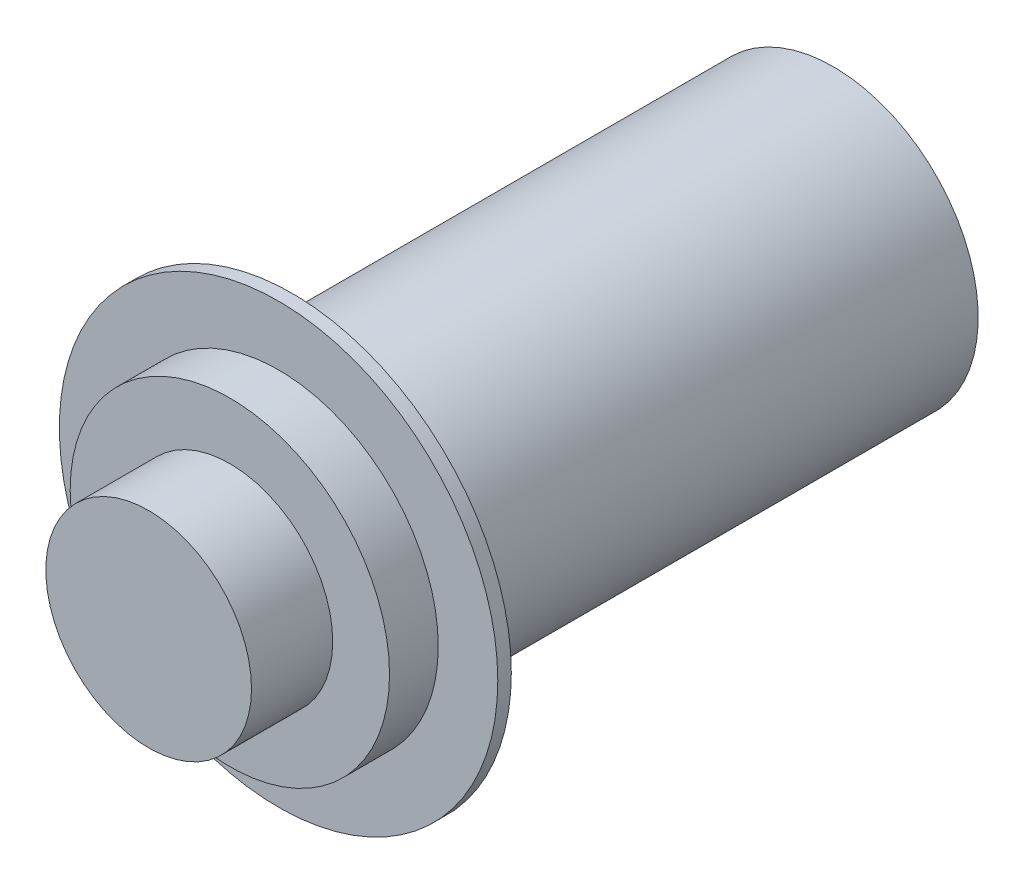
from build123d import *

# Parameters (mm, degrees)
ESQUISSE1_R        = 8.1
BOSS_EXTRU_1_DEPTH = 0.5
ESQUISSE2_R        = 5.9
BOSS_EXTRU_2_DEPTH = 1.8
ESQUISSE3_R        = 3.8
BOSS_EXTRU_3_DEPTH = 3
ESQUISSE4_R        = 5.35
BOSS_EXTRU_4_DEPTH = 20


with BuildPart() as part:
    # Esquisse1 → Boss.-Extru.1 (new body)
    with BuildSketch(Plane.XY):
        Circle(ESQUISSE1_R)
    extrude(amount=BOSS_EXTRU_1_DEPTH)

    # Esquisse2 → Boss.-Extru.2 (add)
    with BuildSketch(Plane.XY.offset(0.5)):
        Circle(ESQUISSE2_R)
    extrude(amount=BOSS_EXTRU_2_DEPTH)

    # Esquisse3 → Boss.-Extru.3 (add)
    with BuildSketch(Plane.XY.offset(2.3)):
        Circle(ESQUISSE3_R)
    extrude(amount=BOSS_EXTRU_3_DEPTH)

    # Esquisse4 → Boss.-Extru.4 (add)
    with BuildSketch(Plane(origin=(0, 0, 0), x_dir=(-1, 0, 0), z_dir=(0, 0, -1))):
        Circle(ESQUISSE4_R)
    extrude(amount=BOSS_EXTRU_4_DEPTH)


solid = part.part
